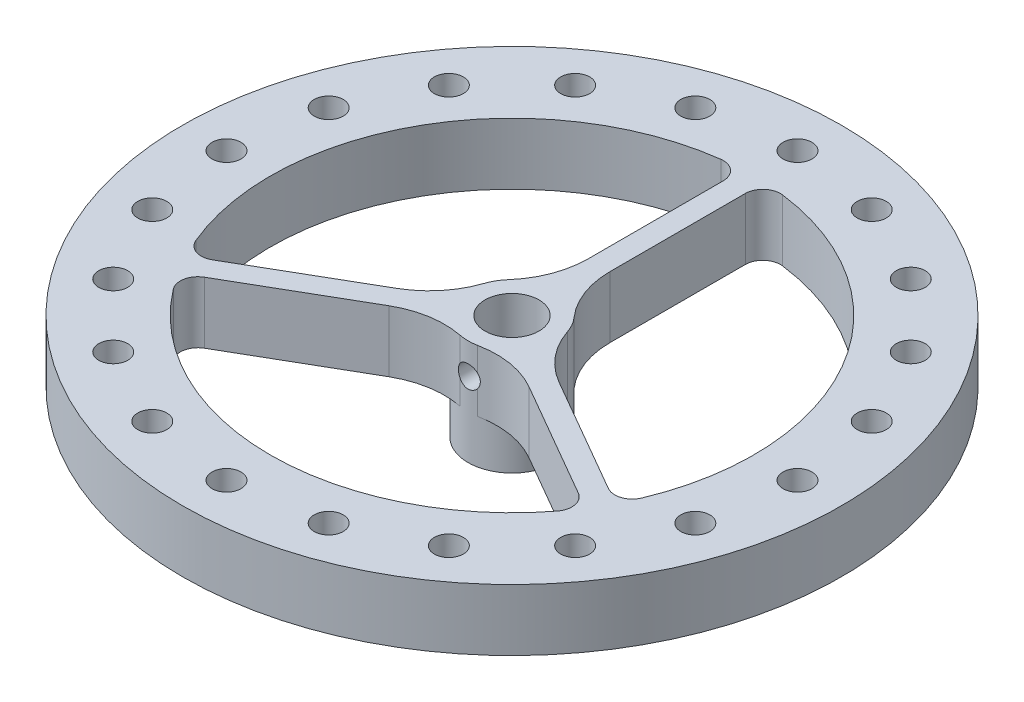
from build123d import *

# Parameters (mm, degrees)
SKETCH1_R           = 5
SKETCH1_R_2         = 3.075
BOSS_EXTRUDE1_DEPTH = 5
SKETCH4_R           = 37.5
SKETCH4_R_2         = 27.5
BOSS_EXTRUDE2_DEPTH = 5
SKETCH5_W           = 2.5
SKETCH5_H           = 22.658770817
BOSS_EXTRUDE3_DEPTH = 5
CIRPATTERN1_COUNT   = 3
SKETCH6_R           = 1.65
CUT_EXTRUDE1_DEPTH  = 5
FILLET1_R           = 10
FILLET2_R           = 2
CIRPATTERN2_COUNT   = 20
SKETCH7_R           = 37.5
BOSS_EXTRUDE4_DEPTH = 2
SKETCH8_R           = 3.075
CUT_EXTRUDE2_DEPTH  = 3
SKETCH9_R           = 1.25
CUT_EXTRUDE3_DEPTH  = 10
SKETCH10_R          = 5
SKETCH10_R_2        = 3.075
BOSS_EXTRUDE5_DEPTH = 5


with BuildPart() as part:
    # Sketch1 → Boss-Extrude1 (new body)
    with BuildSketch(Plane(origin=(0, 0, 0), x_dir=(1, 0, 0), z_dir=(0, 1, 0))):
        Circle(SKETCH1_R)
        Circle(SKETCH1_R_2, mode=Mode.SUBTRACT)
    extrude(amount=BOSS_EXTRUDE1_DEPTH)



with BuildPart() as body_2:
    # Sketch4 → Boss-Extrude2 (new body)
    with BuildSketch(Plane(origin=(0, 0, 0), x_dir=(1, 0, 0), z_dir=(0, 1, 0))):
        Circle(SKETCH4_R)
        Circle(SKETCH4_R_2, mode=Mode.SUBTRACT)
    extrude(amount=BOSS_EXTRUDE2_DEPTH)


with BuildPart() as part_1:
    add(part.part)

    add(body_2.part)  # Boss-Extrude3 merges body 2
    # Sketch5 → Boss-Extrude3 (add)
    with BuildSketch(Plane(origin=(0, 5, 0), x_dir=(1, 0, 0), z_dir=(0, 1, 0))):
        with Locations((0, 16.170614592)):
            Rectangle(SKETCH5_W, SKETCH5_H)
    boss_extrude3 = extrude(amount=-BOSS_EXTRUDE3_DEPTH)

    # CirPattern1: Boss-Extrude3 ×3 about axis
    cirpattern1_axis = Axis((0, 0, 0), (0, 1, 0))
    for i in range(1, CIRPATTERN1_COUNT):
        add(boss_extrude3.rotate(cirpattern1_axis, i * 360 / CIRPATTERN1_COUNT))

    # Sketch6 → Cut-Extrude1 (cut)
    with BuildSketch(Plane(origin=(0, 5, 0), x_dir=(1, 0, 0), z_dir=(0, 1, 0))):
        with Locations((0, 32.48578811)):
            Circle(SKETCH6_R)
    cut_extrude1 = extrude(amount=-CUT_EXTRUDE1_DEPTH, mode=Mode.SUBTRACT)

    # Fillet1
    fillet1_edges = [part_1.edges().sort_by_distance(p)[0] for p in [
        (1.25, 2.5, -4.841229183),
        (-1.25, 2.5, -4.841229183),
        (3.567627458, 2.5, 3.503146346),
        (4.817627458, 2.5, 1.338082837),
        (-4.817627458, 2.5, 1.338082837),
        (-3.567627458, 2.5, 3.503146346),
    ]]
    fillet(fillet1_edges, radius=FILLET1_R)

    # Fillet2
    fillet2_edges = [part_1.edges().sort_by_distance(p)[0] for p in [
        (1.25, 2.5, -27.47157622),
        (-1.25, 2.5, -27.47157622),
        (24.416082888, 2.5, 12.653256355),
        (23.166082888, 2.5, 14.818319865),
        (-24.416082888, 2.5, 12.653256355),
        (-23.166082888, 2.5, 14.818319865),
    ]]
    fillet(fillet2_edges, radius=FILLET2_R)

    # CirPattern2: Cut-Extrude1 ×20 about axis
    cirpattern2_axis = Axis((0, 0, 0), (0, 1, 0))
    for i in range(1, CIRPATTERN2_COUNT):
        add(cut_extrude1.rotate(cirpattern2_axis, i * 360 / CIRPATTERN2_COUNT), mode=Mode.SUBTRACT)

    # Sketch7 → Boss-Extrude4 (add)
    with BuildSketch(Plane.XZ):
        Circle(SKETCH7_R)
        Polygon((11.019921348, 33.915830515), (7.913885555, 33.255622227), (6.932624808, 30.23561218), (9.057399855, 27.875810423), (12.163435648, 28.536018711), (13.144696395, 31.556028758), align=None, mode=Mode.SUBTRACT)
        Polygon((0, 35.66121459), (-2.75, 34.07350135), (-2.75, 30.89807487), (0, 29.310361629), (2.75, 30.89807487), (2.75, 34.07350135), align=None, mode=Mode.SUBTRACT)
        Polygon((20.961136015, 28.850528644), (17.803104853, 29.182451094), (15.936635998, 26.613477107), (17.228198305, 23.712580669), (20.386229467, 23.380658219), (22.252698322, 25.949632206), align=None, mode=Mode.SUBTRACT)
        Polygon((28.850528644, 20.961136015), (25.949632206, 22.252698322), (23.380658219, 20.386229467), (23.712580669, 17.228198305), (26.613477107, 15.936635998), (29.182451094, 17.803104853), align=None, mode=Mode.SUBTRACT)
        Polygon((33.915830515, 11.019921348), (31.556028758, 13.144696395), (28.536018711, 12.163435648), (27.875810423, 9.057399855), (30.23561218, 6.932624808), (33.255622227, 7.913885555), align=None, mode=Mode.SUBTRACT)
        Polygon((35.66121459, 0), (34.07350135, 2.75), (30.89807487, 2.75), (29.310361629, 0), (30.89807487, -2.75), (34.07350135, -2.75), align=None, mode=Mode.SUBTRACT)
        Polygon((33.915830515, -11.019921348), (33.255622227, -7.913885555), (30.23561218, -6.932624808), (27.875810423, -9.057399855), (28.536018711, -12.163435648), (31.556028758, -13.144696395), align=None, mode=Mode.SUBTRACT)
        Polygon((28.850528644, -20.961136015), (29.182451094, -17.803104853), (26.613477107, -15.936635998), (23.712580669, -17.228198305), (23.380658219, -20.386229467), (25.949632206, -22.252698322), align=None, mode=Mode.SUBTRACT)
        Polygon((20.961136015, -28.850528644), (22.252698322, -25.949632206), (20.386229467, -23.380658219), (17.228198305, -23.712580669), (15.936635998, -26.613477107), (17.803104853, -29.182451094), align=None, mode=Mode.SUBTRACT)
        Polygon((11.019921348, -33.915830515), (13.144696395, -31.556028758), (12.163435648, -28.536018711), (9.057399855, -27.875810423), (6.932624808, -30.23561218), (7.913885555, -33.255622227), align=None, mode=Mode.SUBTRACT)
        Polygon((0, -35.66121459), (2.75, -34.07350135), (2.75, -30.89807487), (0, -29.310361629), (-2.75, -30.89807487), (-2.75, -34.07350135), align=None, mode=Mode.SUBTRACT)
        Polygon((-11.019921348, -33.915830515), (-7.913885555, -33.255622227), (-6.932624808, -30.23561218), (-9.057399855, -27.875810423), (-12.163435648, -28.536018711), (-13.144696395, -31.556028758), align=None, mode=Mode.SUBTRACT)
        Polygon((-20.961136015, -28.850528644), (-17.803104853, -29.182451094), (-15.936635998, -26.613477107), (-17.228198305, -23.712580669), (-20.386229467, -23.380658219), (-22.252698322, -25.949632206), align=None, mode=Mode.SUBTRACT)
        Polygon((-28.850528644, -20.961136015), (-25.949632206, -22.252698322), (-23.380658219, -20.386229467), (-23.712580669, -17.228198305), (-26.613477107, -15.936635998), (-29.182451094, -17.803104853), align=None, mode=Mode.SUBTRACT)
        Polygon((-33.915830515, -11.019921348), (-31.556028758, -13.144696395), (-28.536018711, -12.163435648), (-27.875810423, -9.057399855), (-30.23561218, -6.932624808), (-33.255622227, -7.913885555), align=None, mode=Mode.SUBTRACT)
        Polygon((-35.66121459, 0), (-34.07350135, -2.75), (-30.89807487, -2.75), (-29.310361629, 0), (-30.89807487, 2.75), (-34.07350135, 2.75), align=None, mode=Mode.SUBTRACT)
        Polygon((-33.915830515, 11.019921348), (-33.255622227, 7.913885555), (-30.23561218, 6.932624808), (-27.875810423, 9.057399855), (-28.536018711, 12.163435648), (-31.556028758, 13.144696395), align=None, mode=Mode.SUBTRACT)
        Polygon((-28.850528644, 20.961136015), (-29.182451094, 17.803104853), (-26.613477107, 15.936635998), (-23.712580669, 17.228198305), (-23.380658219, 20.386229467), (-25.949632206, 22.252698322), align=None, mode=Mode.SUBTRACT)
        Polygon((-20.961136015, 28.850528644), (-22.252698322, 25.949632206), (-20.386229467, 23.380658219), (-17.228198305, 23.712580669), (-15.936635998, 26.613477107), (-17.803104853, 29.182451094), align=None, mode=Mode.SUBTRACT)
        Polygon((-11.019921348, 33.915830515), (-13.144696395, 31.556028758), (-12.163435648, 28.536018711), (-9.057399855, 27.875810423), (-6.932624808, 30.23561218), (-7.913885555, 33.255622227), align=None, mode=Mode.SUBTRACT)
    extrude(amount=BOSS_EXTRUDE4_DEPTH)

    # Sketch8 → Cut-Extrude2 (cut)
    with BuildSketch(Plane(origin=(0, 0, 0), x_dir=(1, 0, 0), z_dir=(0, 1, 0))):
        Circle(SKETCH8_R)
        with BuildLine():
            Line((-1.25, 9.921567416), (-1.25, 25.292044204))
            ThreePointArc((-1.25, 25.292044204), (-1.928978411, 26.793677302), (-3.504901961, 27.275733945))
            ThreePointArc((-3.504901961, 27.275733945), (-23.815698604, 13.75), (-25.373929484, -10.602532837))
            ThreePointArc((-25.373929484, -10.602532837), (-24.168494409, -11.726294344), (-22.528552794, -11.563490347))
            Line((-22.528552794, -11.563490347), (-9.217329428, -3.878251954))
            ThreePointArc((-9.217329428, -3.878251954), (-6.478395516, -1.551156836), (-4.739109809, 1.594000695))
            ThreePointArc((-4.739109809, 1.594000695), (-4.330127019, 2.5), (-3.75, 3.307189139))
            ThreePointArc((-3.75, 3.307189139), (-1.895856533, 6.386033511), (-1.25, 9.921567416))
        make_face()
        with BuildLine():
            Line((-7.967329428, -6.043315463), (-21.278552794, -13.728553857))
            ThreePointArc((-21.278552794, -13.728553857), (-22.239515999, -15.067382958), (-21.869027523, -16.673201108))
            ThreePointArc((-21.869027523, -16.673201108), (0, -27.5), (21.869027523, -16.673201108))
            ThreePointArc((21.869027523, -16.673201108), (22.239515999, -15.067382958), (21.278552794, -13.728553857))
            Line((21.278552794, -13.728553857), (7.967329428, -6.043315463))
            ThreePointArc((7.967329428, -6.043315463), (4.582538983, -4.834876675), (0.989109809, -4.901189834))
            ThreePointArc((0.989109809, -4.901189834), (0, -5), (-0.989109809, -4.901189834))
            ThreePointArc((-0.989109809, -4.901189834), (-4.582538983, -4.834876675), (-7.967329428, -6.043315463))
        make_face()
        with BuildLine():
            Line((1.25, 25.292044204), (1.25, 9.921567416))
            ThreePointArc((1.25, 9.921567416), (1.895856533, 6.386033511), (3.75, 3.307189139))
            ThreePointArc((3.75, 3.307189139), (4.330127019, 2.5), (4.739109809, 1.594000695))
            ThreePointArc((4.739109809, 1.594000695), (6.478395516, -1.551156836), (9.217329428, -3.878251954))
            Line((9.217329428, -3.878251954), (22.528552794, -11.563490347))
            ThreePointArc((22.528552794, -11.563490347), (24.168494409, -11.726294344), (25.373929484, -10.602532837))
            ThreePointArc((25.373929484, -10.602532837), (23.815698604, 13.75), (3.504901961, 27.275733945))
            ThreePointArc((3.504901961, 27.275733945), (1.928978411, 26.793677302), (1.25, 25.292044204))
        make_face()
    extrude(amount=-CUT_EXTRUDE2_DEPTH, mode=Mode.SUBTRACT)

    # Sketch9 → Cut-Extrude3 (cut)
    with BuildSketch(Plane.XY):
        with Locations((0, 1.5)):
            Circle(SKETCH9_R)
    extrude(amount=CUT_EXTRUDE3_DEPTH, mode=Mode.SUBTRACT)

    # Sketch10 → Boss-Extrude5 (add)
    with BuildSketch(Plane.XZ.offset(2)):
        Circle(SKETCH10_R)
        Circle(SKETCH10_R_2, mode=Mode.SUBTRACT)
    extrude(amount=BOSS_EXTRUDE5_DEPTH)


solid = part_1.part
